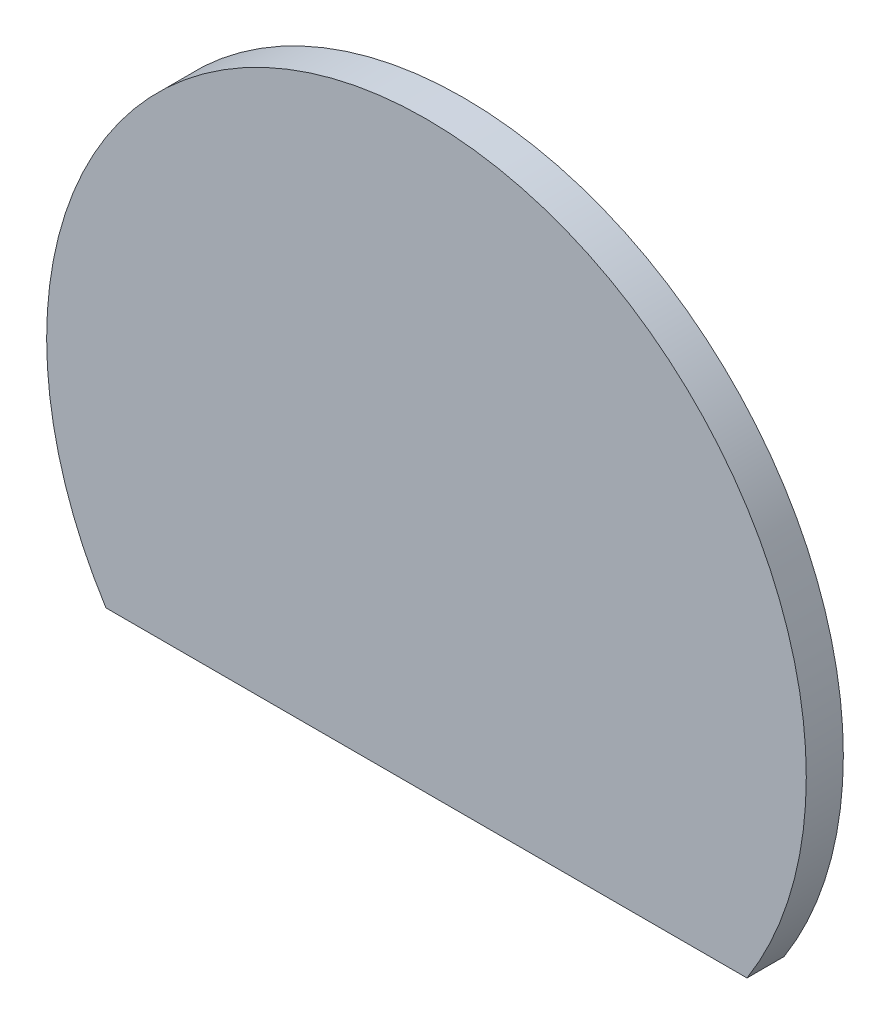
from build123d import *

# Parameters (mm, degrees)
BOSS_EXTRUDE1_DEPTH = 1
SKETCH1_4_R         = 5.5
SKETCH1_4_R_2       = 4.5
BOSS_EXTRUDE2_DEPTH = 2


with BuildPart() as part:
    # Sketch1 → Boss-Extrude1 (new body)
    with BuildSketch(Plane.XY):
        with BuildLine():
            ThreePointArc((8.649421946, -5.5), (0, 10.25), (-8.649421946, -5.5))
            Line((-8.649421946, -5.5), (8.649421946, -5.5))
        make_face()
    extrude(amount=BOSS_EXTRUDE1_DEPTH)

    # Sketch1_4 → Boss-Extrude2 (add)
    with BuildSketch(Plane.XY):
        Circle(SKETCH1_4_R)
        Circle(SKETCH1_4_R_2, mode=Mode.SUBTRACT)
    extrude(amount=-BOSS_EXTRUDE2_DEPTH)


solid = part.part
